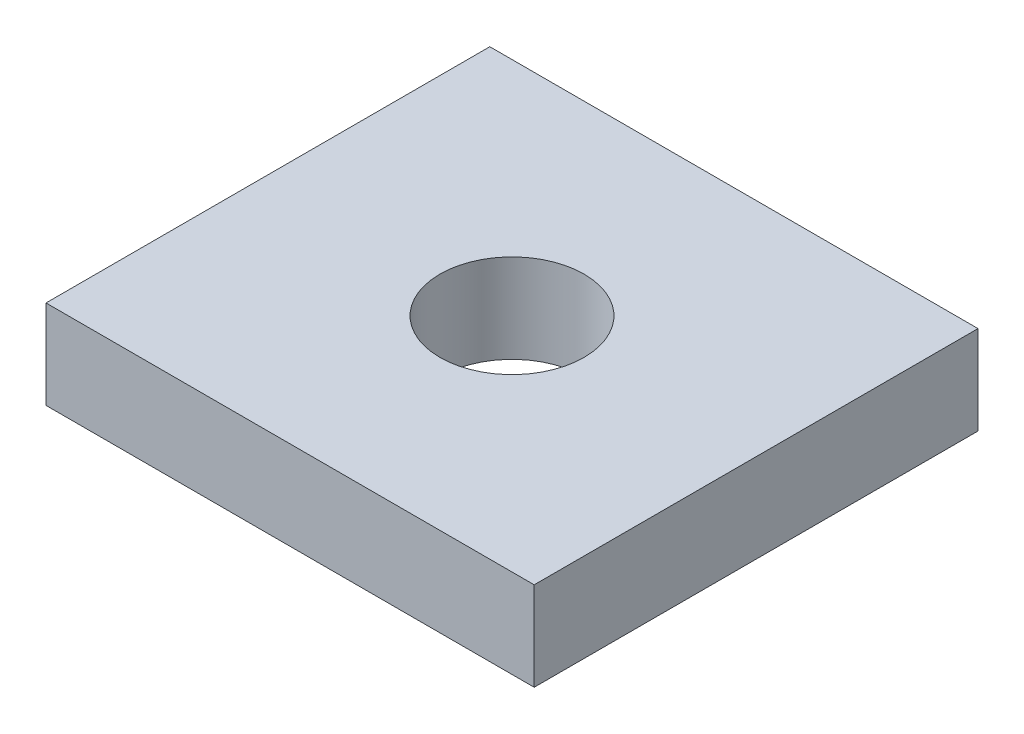
from build123d import *

# Parameters (mm, degrees)
ESQUISSE2_W        = 22
ESQUISSE2_H        = 20
ESQUISSE2_R        = 3.25
BOSS_EXTRU_1_DEPTH = 4


with BuildPart() as part:
    # Esquisse2 → Boss.-Extru.1 (new body)
    with BuildSketch(Plane(origin=(0, 0, 0), x_dir=(1, 0, 0), z_dir=(0, 1, 0))):
        Rectangle(ESQUISSE2_W, ESQUISSE2_H)
        Circle(ESQUISSE2_R, mode=Mode.SUBTRACT)
    extrude(amount=BOSS_EXTRU_1_DEPTH)


solid = part.part
